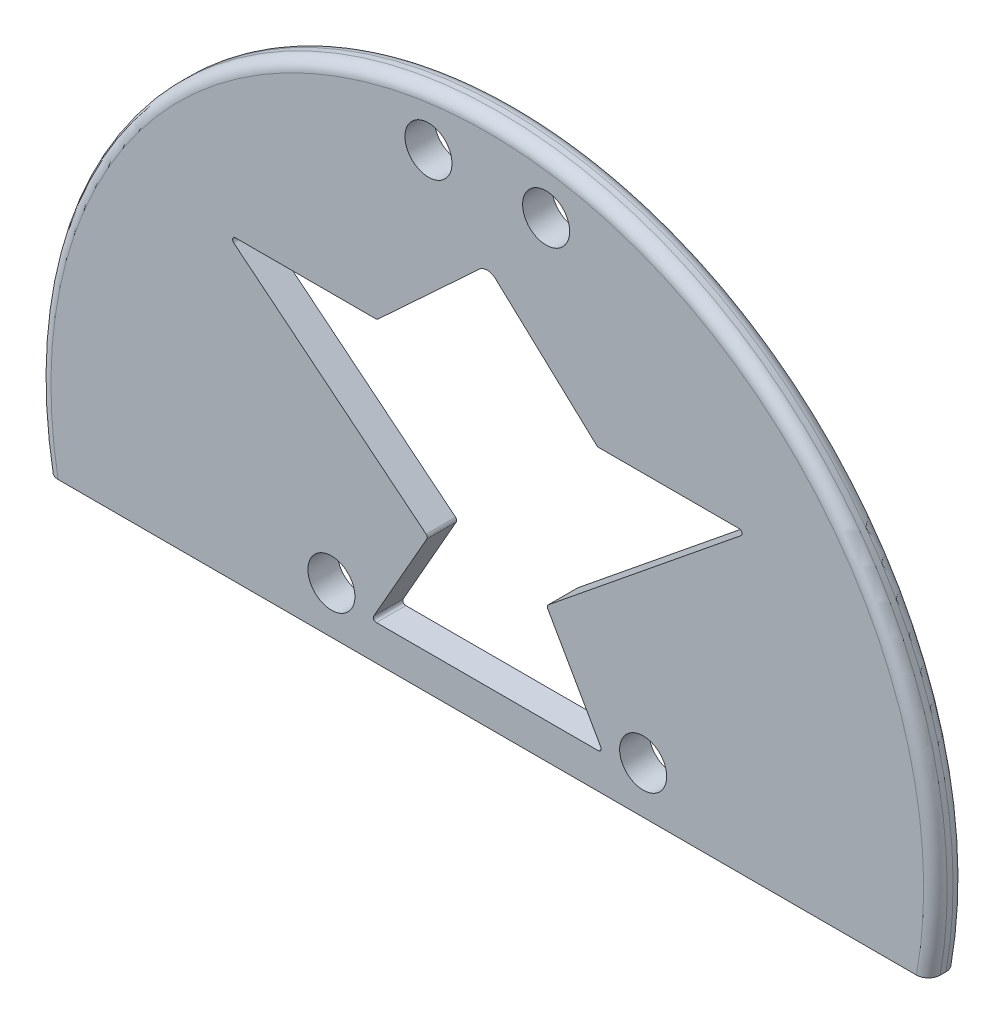
from build123d import *

# Parameters (mm, degrees)
BOSS_EXTRUDE1_DEPTH = 5
SKETCH2_R           = 4
CUT_EXTRUDE1_DEPTH  = 5
CUT_EXTRUDE2_DEPTH  = 5
FILLET1_R           = 2


with BuildPart() as part:
    # Sketch1 → Boss-Extrude1 (new body)
    with BuildSketch(Plane.XY):
        with BuildLine():
            Line((-75, 0), (75, 0))
            ThreePointArc((75, 0), (0, 89.621051558), (-75, 0))
        make_face()
    extrude(amount=BOSS_EXTRUDE1_DEPTH)

    # Sketch2 → Cut-Extrude1 (cut)
    with BuildSketch(Plane.XY.offset(5)):
        with Locations((26.5, 8)):
            Circle(SKETCH2_R)
        with Locations((10, 80)):
            Circle(SKETCH2_R)
        with Locations((-10, 80)):
            Circle(SKETCH2_R)
        with Locations((-26.5, 8)):
            Circle(SKETCH2_R)
    extrude(amount=-CUT_EXTRUDE1_DEPTH, mode=Mode.SUBTRACT)

    # Sketch3 → Cut-Extrude2 (cut)
    with BuildSketch(Plane.XY.offset(5)):
        with BuildLine():
            Line((18.867867545, 5.996639034), (-18.867867545, 5.996639034))
            ThreePointArc((-18.867867545, 5.996639034), (-19.300154289, 6.245385832), (-19.302321259, 6.744126348))
            Line((-19.302321259, 6.744126348), (-10.267508213, 22.604365842))
            ThreePointArc((-10.267508213, 22.604365842), (-10.210571808, 22.944242288), (-10.387060948, 23.240231031))
            Line((-10.387060948, 23.240231031), (-43.118302779, 49.77907576))
            ThreePointArc((-43.118302779, 49.77907576), (-43.274670798, 50.334503122), (-42.8034018, 50.667453634))
            Line((-42.8034018, 50.667453634), (-18.945540234, 50.667453634))
            ThreePointArc((-18.945540234, 50.667453634), (-18.763089024, 50.70193075), (-18.605799379, 50.80060741))
            Line((-18.605799379, 50.80060741), (-1.358963418, 66.773116887))
            ThreePointArc((-1.358963418, 66.773116887), (0, 67.305731992), (1.358963418, 66.773116887))
            Line((1.358963418, 66.773116887), (18.605799379, 50.80060741))
            ThreePointArc((18.605799379, 50.80060741), (18.763089024, 50.70193075), (18.945540234, 50.667453634))
            Line((18.945540234, 50.667453634), (42.8034018, 50.667453634))
            ThreePointArc((42.8034018, 50.667453634), (43.274670798, 50.334503122), (43.118302779, 49.77907576))
            Line((43.118302779, 49.77907576), (10.387060948, 23.240231031))
            ThreePointArc((10.387060948, 23.240231031), (10.210571808, 22.944242288), (10.267508213, 22.604365842))
            Line((10.267508213, 22.604365842), (19.302321259, 6.744126348))
            ThreePointArc((19.302321259, 6.744126348), (19.300154289, 6.245385832), (18.867867545, 5.996639034))
        make_face()
    extrude(amount=-CUT_EXTRUDE2_DEPTH, mode=Mode.SUBTRACT)

    # Fillet1
    fillet1_edges = [part.edges().sort_by_distance(p)[0] for p in [
        (0, 89.621051558, 0),
        (0, 89.621051558, 5),
    ]]
    fillet(fillet1_edges, radius=FILLET1_R)


solid = part.part
